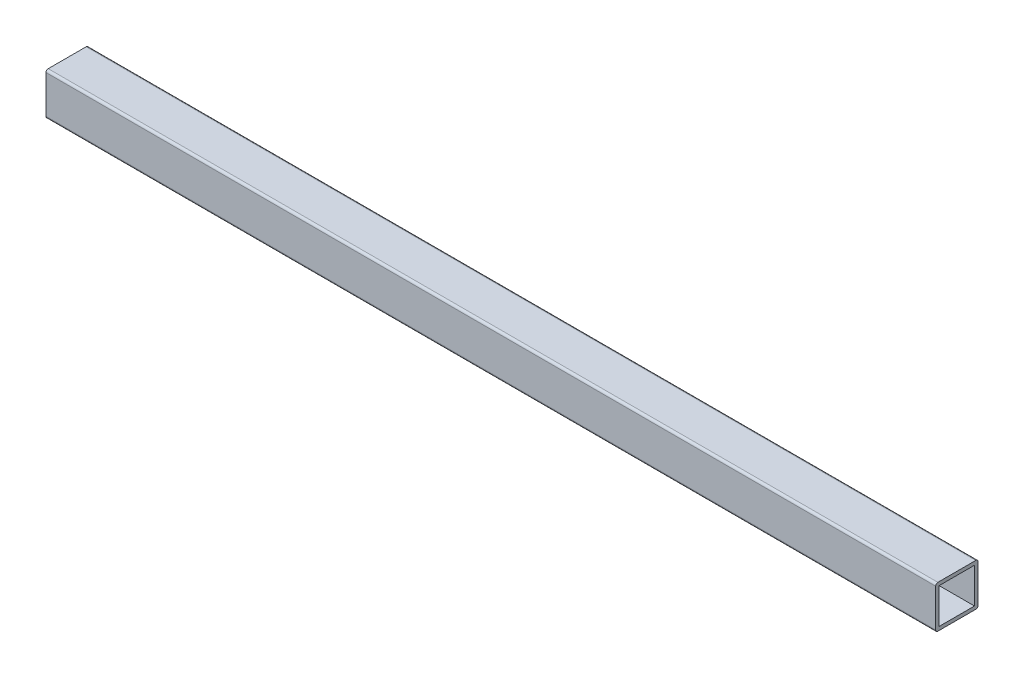
from build123d import *

# Parameters (mm, degrees)
SKETCH2_W           = 19.05
SKETCH2_H           = 19.05
SKETCH2_W_2         = 15.875
SKETCH2_H_2         = 15.875
BOSS_EXTRUDE1_DEPTH = 400
FILLET1_R           = 1


with BuildPart() as part:
    # Sketch2 → Boss-Extrude1 (new body)
    with BuildSketch(Plane(origin=(0, 0, 0), x_dir=(0, 0, -1), z_dir=(1, 0, 0))):
        Rectangle(SKETCH2_W, SKETCH2_H)
        Rectangle(SKETCH2_W_2, SKETCH2_H_2, mode=Mode.SUBTRACT)
    extrude(amount=BOSS_EXTRUDE1_DEPTH)

    # Fillet1
    fillet1_edges = [part.edges().sort_by_distance(p)[0] for p in [
        (200, -9.525, -9.525),
        (200, -9.525, 9.525),
        (200, 9.525, 9.525),
        (200, 9.525, -9.525),
    ]]
    fillet(fillet1_edges, radius=FILLET1_R)


solid = part.part
